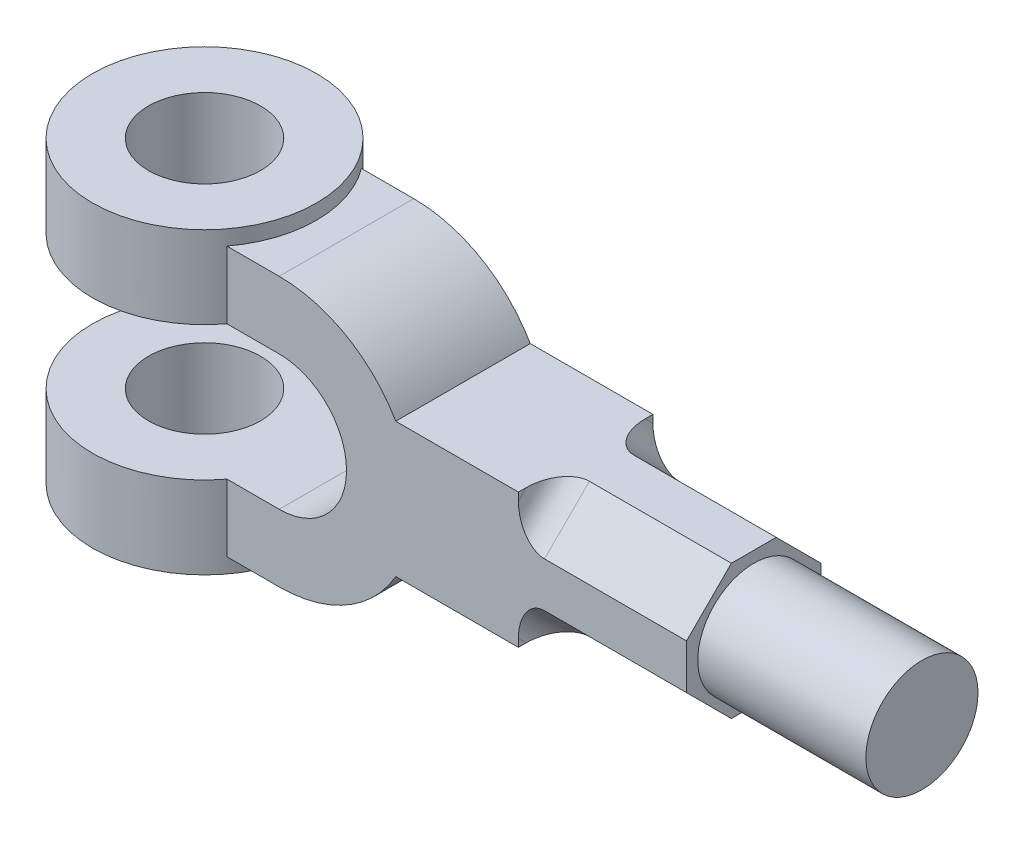
from build123d import *

# Parameters (mm, degrees)
BOSS_EXTRUDE1_DEPTH = 18
SKETCH2_R           = 30
BOSS_EXTRUDE2_DEPTH = 22
SKETCH3_R           = 30
BOSS_EXTRUDE3_DEPTH = 22
SKETCH4_R           = 15
CUT_EXTRUDE1_DEPTH  = 81
CUT_EXTRUDE2_DEPTH  = 45
FILLET1_R           = 7
SKETCH6_R           = 15
BOSS_EXTRUDE4_DEPTH = 45


with BuildPart() as part:
    # Sketch1 → Boss-Extrude1 (new body, symmetric)
    with BuildSketch(Plane.XY):
        with BuildLine():
            Line((31.176914536, 18), (109, 18))
            Line((109, 18), (109, -18))
            Line((109, -18), (31.176914536, -18))
            ThreePointArc((31.176914536, -18), (18, -31.176914536), (0, -36))
            Line((0, -36), (-38, -36))
            Line((-38, -36), (-38, -18))
            Line((-38, -18), (0, -18))
            ThreePointArc((0, -18), (18, 0), (0, 18))
            Line((0, 18), (-38, 18))
            Line((-38, 18), (-38, 36))
            Line((-38, 36), (0, 36))
            ThreePointArc((0, 36), (18, 31.176914536), (31.176914536, 18))
        make_face()
    extrude(amount=BOSS_EXTRUDE1_DEPTH, both=True)

    # Sketch2 → Boss-Extrude2 (add)
    with BuildSketch(Plane.XZ.offset(-18)):
        with Locations((-38, 0)):
            Circle(SKETCH2_R)
    extrude(amount=-BOSS_EXTRUDE2_DEPTH)

    # Sketch3 → Boss-Extrude3 (add)
    with BuildSketch(Plane(origin=(0, -18, 0), x_dir=(1, 0, 0), z_dir=(0, 1, 0))):
        with Locations((-38, 0)):
            Circle(SKETCH3_R)
    extrude(amount=-BOSS_EXTRUDE3_DEPTH)

    # Sketch4 → Cut-Extrude1 (cut, through all)
    with BuildSketch(Plane(origin=(0, 40, 0), x_dir=(1, 0, 0), z_dir=(0, 1, 0))):
        with Locations((-38, 0)):
            Circle(SKETCH4_R)
    extrude(amount=-CUT_EXTRUDE1_DEPTH, mode=Mode.SUBTRACT)

    # Sketch5 → Cut-Extrude2 (cut)
    with BuildSketch(Plane(origin=(109, 0, 0), x_dir=(0, 0, -1), z_dir=(1, 0, 0))):
        Polygon((6, 18), (18, 6), (18, 18), align=None)
        Polygon((18, -18), (18, -6), (6, -18), align=None)
        Polygon((-18, -18), (-6, -18), (-18, -6), align=None)
        Polygon((-18, 18), (-18, 6), (-6, 18), align=None)
    extrude(amount=-CUT_EXTRUDE2_DEPTH, mode=Mode.SUBTRACT)

    # Fillet1
    fillet1_edges = [part.edges().sort_by_distance(p)[0] for p in [
        (64, 12, 12),
        (64, -12, 12),
        (64, -12, -12),
        (64, 12, -12),
    ]]
    fillet(fillet1_edges, radius=FILLET1_R)

    # Sketch6 → Boss-Extrude4 (add)
    with BuildSketch(Plane(origin=(109, 0, 0), x_dir=(0, 0, -1), z_dir=(1, 0, 0))):
        Circle(SKETCH6_R)
    extrude(amount=BOSS_EXTRUDE4_DEPTH)


solid = part.part
